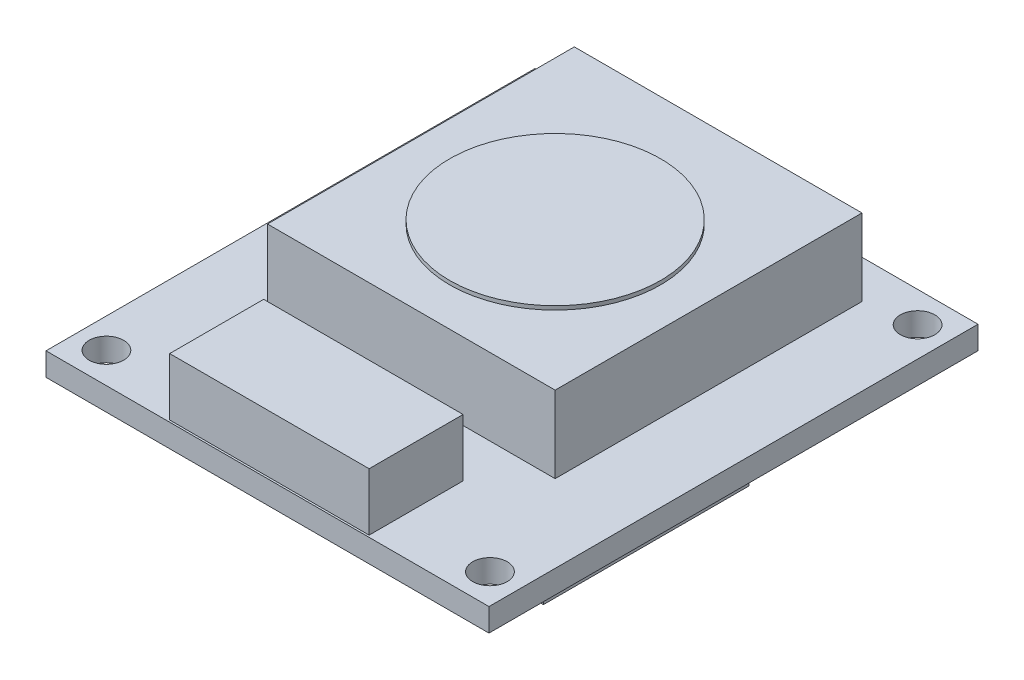
from build123d import *

# Parameters (mm, degrees)
SKETCH_1_W      = 23.1
SKETCH_1_H      = 25.5
SKETCH_1_R      = 0.9
EXTRUDE_1_DEPTH = 1.2
SKETCH_2_W      = 15
SKETCH_2_H      = 16
EXTRUDE_2_DEPTH = 4
SKETCH_3_R      = 5.5
EXTRUDE_3_DEPTH = 0.2
SKETCH_4_W      = 10.4
SKETCH_4_H      = 4.9
EXTRUDE_4_DEPTH = 3
SKETCH_5_W      = 7.083649358
SKETCH_5_H      = 16.349953635
SKETCH_5_W_2    = 1.366011138
SKETCH_5_H_2    = 2.325890212
SKETCH_5_W_3    = 1.835080991
SKETCH_5_H_3    = 1.91855554
SKETCH_5_W_4    = 3.175010274
SKETCH_5_H_4    = 13.27010499
SKETCH_5_W_5    = 4.111087422
SKETCH_5_H_5    = 2.03375188
SKETCH_5_W_6    = 5.947363934
SKETCH_5_H_6    = 10.708861721
EXTRUDE_5_DEPTH = 0.8


with BuildPart() as part:
    # 草图1 → 凸台-拉伸1 (new body)
    with BuildSketch(Plane(origin=(0, 0, 0), x_dir=(1, 0, 0), z_dir=(0, 1, 0))):
        Rectangle(SKETCH_1_W, SKETCH_1_H)
        with Locations((10, 11.15)):
            Circle(SKETCH_1_R, mode=Mode.SUBTRACT)
        with Locations((-10, 11.15)):
            Circle(SKETCH_1_R, mode=Mode.SUBTRACT)
        with Locations((10, -11.15)):
            Circle(SKETCH_1_R, mode=Mode.SUBTRACT)
        with Locations((-10, -11.15)):
            Circle(SKETCH_1_R, mode=Mode.SUBTRACT)
    extrude(amount=EXTRUDE_1_DEPTH)

    # 草图2 → 凸台-拉伸2 (add)
    with BuildSketch(Plane(origin=(0, 1.2, 0), x_dir=(1, 0, 0), z_dir=(0, 1, 0))):
        with Locations((0, 2.75)):
            Rectangle(SKETCH_2_W, SKETCH_2_H)
    extrude(amount=EXTRUDE_2_DEPTH)

    # 草图3 → 凸台-拉伸3 (add)
    with BuildSketch(Plane(origin=(0, 5.2, 0), x_dir=(1, 0, 0), z_dir=(0, 1, 0))):
        with Locations((0, 2.25)):
            Circle(SKETCH_3_R)
    extrude(amount=EXTRUDE_3_DEPTH)

    # 草图4 → 凸台-拉伸4 (add)
    with BuildSketch(Plane(origin=(0, 1.2, 0), x_dir=(1, 0, 0), z_dir=(0, 1, 0))):
        with Locations((0, -10.2)):
            Rectangle(SKETCH_4_W, SKETCH_4_H)
    extrude(amount=EXTRUDE_4_DEPTH)

    # 草图5 → 凸台-拉伸5 (add)
    with BuildSketch(Plane.XZ):
        with Locations((-0.031355778, 3.113299148)):
            Rectangle(SKETCH_5_W, SKETCH_5_H)
        with Locations((-3.127935708, -7.143071696)):
            Rectangle(SKETCH_5_W_2, SKETCH_5_H_2)
        with Locations((7.782140552, -3.170898119)):
            Rectangle(SKETCH_5_W_3, SKETCH_5_H_3)
        with Locations((-7.914690991, 2.157353718)):
            Rectangle(SKETCH_5_W_4, SKETCH_5_H_4)
        with Locations((-8.028697172, -7.143071696)):
            Rectangle(SKETCH_5_W_5, SKETCH_5_H_5)
        with Locations((7.909232795, 3.891185517)):
            Rectangle(SKETCH_5_W_6, SKETCH_5_H_6)
    extrude(amount=EXTRUDE_5_DEPTH)


solid = part.part
